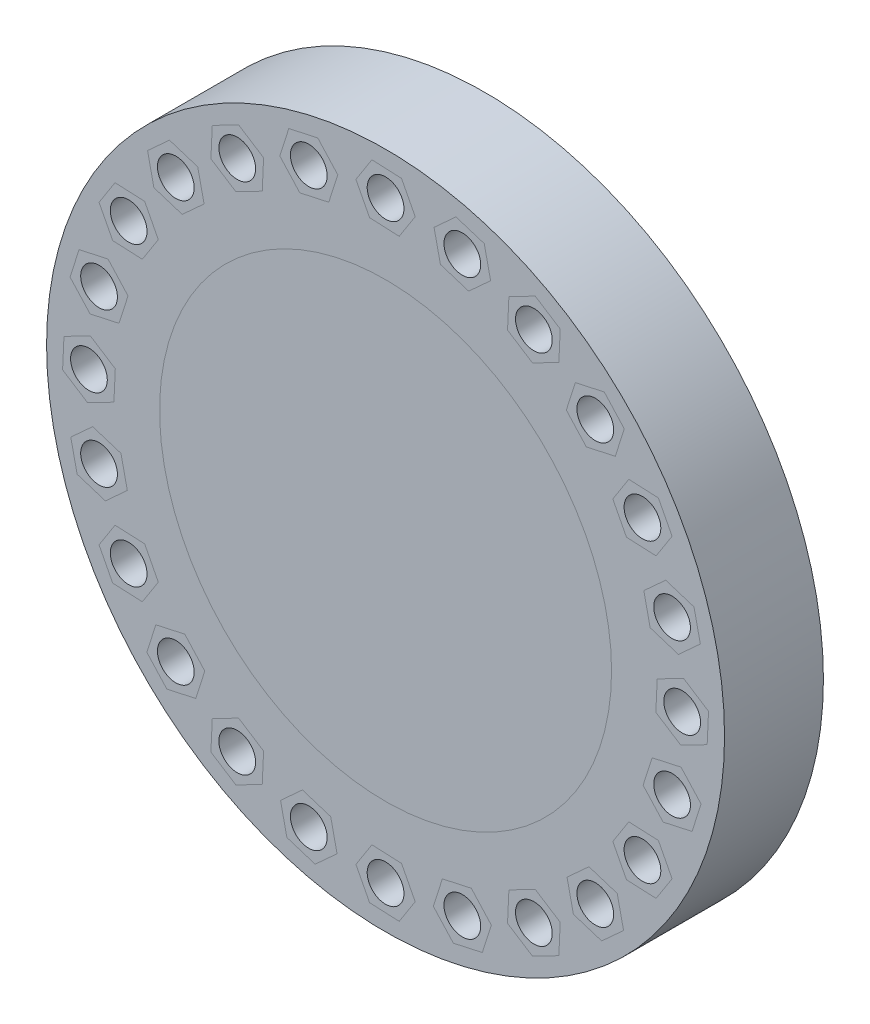
from build123d import *

# Parameters (mm, degrees)
SKETCH1_R           = 304.8
BOSS_EXTRUDE1_DEPTH = 88.9
SKETCH2_R           = 16.51
CUT_EXTRUDE6_DEPTH  = 88.9


with BuildPart() as part:
    # Sketch1 → Boss-Extrude1 (new body)
    with BuildSketch(Plane.XY):
        Circle(SKETCH1_R)
    extrude(amount=BOSS_EXTRUDE1_DEPTH)

    # Sketch2 → Cut-Extrude6 (cut)
    with BuildSketch(Plane.XY.offset(88.9)):
        with Locations((0, 266.7)):
            Circle(SKETCH2_R)
        with Locations((69.027039329, 257.612417871)):
            Circle(SKETCH2_R)
        with Locations((133.35, 230.968975189)):
            Circle(SKETCH2_R)
        with Locations((188.585378542, 188.585378542)):
            Circle(SKETCH2_R)
        with Locations((230.968975189, 133.35)):
            Circle(SKETCH2_R)
        with Locations((257.612417871, 69.027039329)):
            Circle(SKETCH2_R)
        with Locations((266.7, 0)):
            Circle(SKETCH2_R)
        with Locations((257.612417871, -69.027039329)):
            Circle(SKETCH2_R)
        with Locations((230.968975189, -133.35)):
            Circle(SKETCH2_R)
        with Locations((188.585378542, -188.585378542)):
            Circle(SKETCH2_R)
        with Locations((133.35, -230.968975189)):
            Circle(SKETCH2_R)
        with Locations((69.027039329, -257.612417871)):
            Circle(SKETCH2_R)
        with Locations((0, -266.7)):
            Circle(SKETCH2_R)
        with Locations((-69.027039329, -257.612417871)):
            Circle(SKETCH2_R)
        with Locations((-133.35, -230.968975189)):
            Circle(SKETCH2_R)
        with Locations((-188.585378542, -188.585378542)):
            Circle(SKETCH2_R)
        with Locations((-230.968975189, -133.35)):
            Circle(SKETCH2_R)
        with Locations((-257.612417871, -69.027039329)):
            Circle(SKETCH2_R)
        with Locations((-266.7, 0)):
            Circle(SKETCH2_R)
        with Locations((-257.612417871, 69.027039329)):
            Circle(SKETCH2_R)
        with Locations((-230.968975189, 133.35)):
            Circle(SKETCH2_R)
        with Locations((-188.585378542, 188.585378542)):
            Circle(SKETCH2_R)
        with Locations((-133.35, 230.968975189)):
            Circle(SKETCH2_R)
        with Locations((-69.027039329, 257.612417871)):
            Circle(SKETCH2_R)
    extrude(amount=-CUT_EXTRUDE6_DEPTH, mode=Mode.SUBTRACT)


solid = part.part
